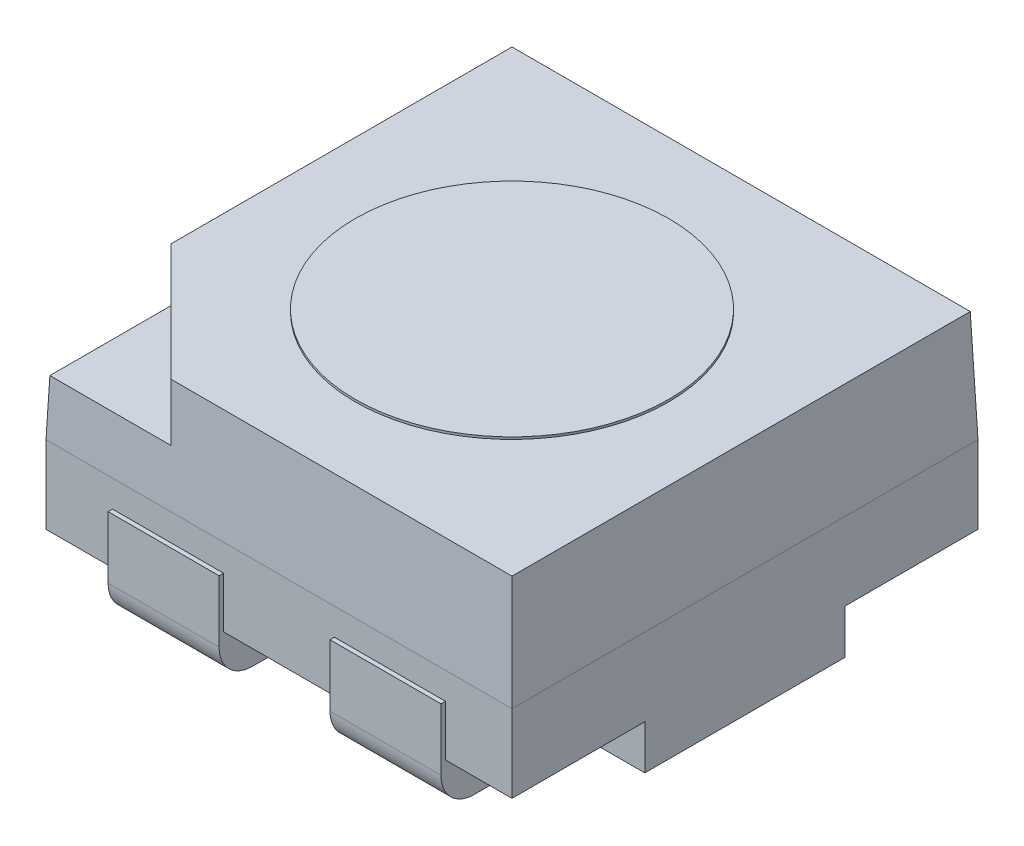
from build123d import *

# Parameters (mm, degrees)
ESQUISSE1_W                  = 2.1
ESQUISSE1_H                  = 2.1
BOSS_EXTRU_1_DEPTH           = 0.35
ESQUISSE2_W                  = 2.1
ESQUISSE2_H                  = 2.1
BOSS_EXTRU_2_DEPTH           = 0.5
BOSS_EXTRU_2_TAPER           = 2
ESQUISSE3_R                  = 0.70602874
BOSS_EXTRU_3_DEPTH           = 0.01
ENL_V_MAT_EXTRU_2_DEPTH      = 0.25
ESQUISSE5_W                  = 0.5
ESQUISSE5_H                  = 0.5
BOSS_EXTRU_4_DEPTH           = 0.2
ESQUISSE6_W                  = 0.5
ESQUISSE6_H                  = 0.428841244
ENL_V_MAT_EXTRU_3_DEPTH      = 0.2
ESQUISSE8_W                  = 0.5
ESQUISSE8_H                  = 0.428841244
ENL_V_MAT_EXTRU_4_DEPTH      = 0.2
ESQUISSE9_W                  = 0.5
ESQUISSE9_H                  = 0.428841244
BOSS_EXTRU_5_DEPTH           = 0.22
ESQUISSE10_W                 = 0.5
ESQUISSE10_H                 = 0.428841244
BOSS_EXTRU_6_DEPTH           = 0.22
ENL_V_MAT_EXTRU_5_DEPTH      = 2.8000001
CORPS_D_PLACER_COPIER1_ANGLE = 180
ESQUISSE14_W                 = 0.903052764
ESQUISSE14_H                 = 2.1
BOSS_EXTRU_7_DEPTH           = 0.2
CORPS_D_PLACER_COPIER2_ANGLE = 90


with BuildPart() as part:
    # Esquisse1 → Boss.-Extru.1 (new body)
    with BuildSketch(Plane(origin=(0, 0, 0), x_dir=(1, 0, 0), z_dir=(0, 1, 0))):
        Rectangle(ESQUISSE1_W, ESQUISSE1_H)
    extrude(amount=BOSS_EXTRU_1_DEPTH)

    # Esquisse5 → Boss.-Extru.4 (add)
    with BuildSketch(Plane.XZ):
        with Locations((0.8, 0.5)):
            Rectangle(ESQUISSE5_W, ESQUISSE5_H)
        with Locations((0.8, -0.5)):
            Rectangle(ESQUISSE5_W, ESQUISSE5_H)
        with Locations((-0.8, 0.5)):
            Rectangle(ESQUISSE5_W, ESQUISSE5_H)
        with Locations((-0.8, -0.5)):
            Rectangle(ESQUISSE5_W, ESQUISSE5_H)
    extrude(amount=BOSS_EXTRU_4_DEPTH)

    # Esquisse6 → Enlèv. mat.-Extru.3 (cut)
    with BuildSketch(Plane.ZY.offset(1.05)):
        with Locations((-0.5, 0.014420622)):
            Rectangle(ESQUISSE6_W, ESQUISSE6_H)
        with Locations((0.5, 0.014420622)):
            Rectangle(ESQUISSE6_W, ESQUISSE6_H)
    extrude(amount=-ENL_V_MAT_EXTRU_3_DEPTH, mode=Mode.SUBTRACT)

    # Esquisse8 → Enlèv. mat.-Extru.4 (cut)
    with BuildSketch(Plane(origin=(1.05, 0, 0), x_dir=(0, 0, -1), z_dir=(1, 0, 0))):
        with Locations((-0.5, 0.014420622)):
            Rectangle(ESQUISSE8_W, ESQUISSE8_H)
        with Locations((0.5, 0.014420622)):
            Rectangle(ESQUISSE8_W, ESQUISSE8_H)
    extrude(amount=-ENL_V_MAT_EXTRU_4_DEPTH, mode=Mode.SUBTRACT)

    # Esquisse9 → Boss.-Extru.5 (add)
    with BuildSketch(Plane.ZY.offset(0.85)):
        with Locations((-0.5, 0.014420622)):
            Rectangle(ESQUISSE9_W, ESQUISSE9_H)
        with Locations((0.5, 0.014420622)):
            Rectangle(ESQUISSE9_W, ESQUISSE9_H)
    extrude(amount=BOSS_EXTRU_5_DEPTH)

    # Esquisse10 → Boss.-Extru.6 (add)
    with BuildSketch(Plane(origin=(0.85, 0, 0), x_dir=(0, 0, -1), z_dir=(1, 0, 0))):
        with Locations((-0.5, 0.014420622)):
            Rectangle(ESQUISSE10_W, ESQUISSE10_H)
        with Locations((0.5, 0.014420622)):
            Rectangle(ESQUISSE10_W, ESQUISSE10_H)
    extrude(amount=BOSS_EXTRU_6_DEPTH)

    # Esquisse12 → Enlèv. mat.-Extru.5 (cut, through all)
    with BuildSketch(Plane.XY.offset(0.75)):
        with BuildLine():
            Line((-0.92, -0.2), (-1.261390645, -0.2))
            Line((-1.261390645, -0.2), (-1.261390645, 0))
            Line((-1.261390645, 0), (-1.07, 0))
            Line((-1.07, 0), (-1.07, -0.05))
            ThreePointArc((-1.07, -0.05), (-1.026066017, -0.156066017), (-0.92, -0.2))
        make_face()
        with BuildLine():
            Line((0.92, -0.2), (1.248419925, -0.2))
            Line((1.248419925, -0.2), (1.248419925, 0))
            Line((1.248419925, 0), (1.07, 0))
            Line((1.07, 0), (1.07, -0.05))
            ThreePointArc((1.07, -0.05), (1.026066017, -0.156066017), (0.92, -0.2))
        make_face()
    extrude(amount=-ENL_V_MAT_EXTRU_5_DEPTH, mode=Mode.SUBTRACT)


with BuildPart() as body_2:
    # Esquisse2 → Boss.-Extru.2 (new body)
    with BuildSketch(Plane(origin=(0, 0.35, 0), x_dir=(1, 0, 0), z_dir=(0, 1, 0))):
        Rectangle(ESQUISSE2_W, ESQUISSE2_H)
    extrude(amount=BOSS_EXTRU_2_DEPTH, taper=BOSS_EXTRU_2_TAPER)

    # Esquisse3 → Boss.-Extru.3 (add)
    with BuildSketch(Plane(origin=(0, 0.85, 0), x_dir=(1, 0, 0), z_dir=(0, 1, 0))):
        Circle(ESQUISSE3_R)
    extrude(amount=BOSS_EXTRU_3_DEPTH)

    # Esquisse4 → Enlèv. mat.-Extru.2 (cut)
    with BuildSketch(Plane(origin=(0, 0.85, 0), x_dir=(1, 0, 0), z_dir=(0, 1, 0))):
        Polygon((1.094208492, -1.095993476), (1.094208492, -0.443692637), (0.439455394, -1.095993476), align=None)
    extrude(amount=-ENL_V_MAT_EXTRU_2_DEPTH, mode=Mode.SUBTRACT)


with BuildPart() as body_2_1:
    # Corps-Déplacer/Copier1: moved
    add(body_2.part.rotate(Axis((0, 0, 0), (0, 1, 0)), CORPS_D_PLACER_COPIER1_ANGLE))


with BuildPart() as part_1:
    # Corps-Déplacer/Copier1: moved
    add(part.part.rotate(Axis((0, 0, 0), (0, 1, 0)), CORPS_D_PLACER_COPIER1_ANGLE))

    # Esquisse14 → Boss.-Extru.7 (add)
    with BuildSketch(Plane(origin=(0, 0, 0), x_dir=(-1, 0, 0), z_dir=(0, -1, 0))):
        Rectangle(ESQUISSE14_W, ESQUISSE14_H)
    extrude(amount=BOSS_EXTRU_7_DEPTH)


with BuildPart() as body_2_2:
    # Corps-Déplacer/Copier2: moved
    add(body_2_1.part.rotate(Axis((0, 0, 0), (0, 1, 0)), CORPS_D_PLACER_COPIER2_ANGLE))


with BuildPart() as part_2:
    # Corps-Déplacer/Copier2: moved
    add(part_1.part.rotate(Axis((0, 0, 0), (0, 1, 0)), CORPS_D_PLACER_COPIER2_ANGLE))


solid = Compound([body_2_2.part, part_2.part])
